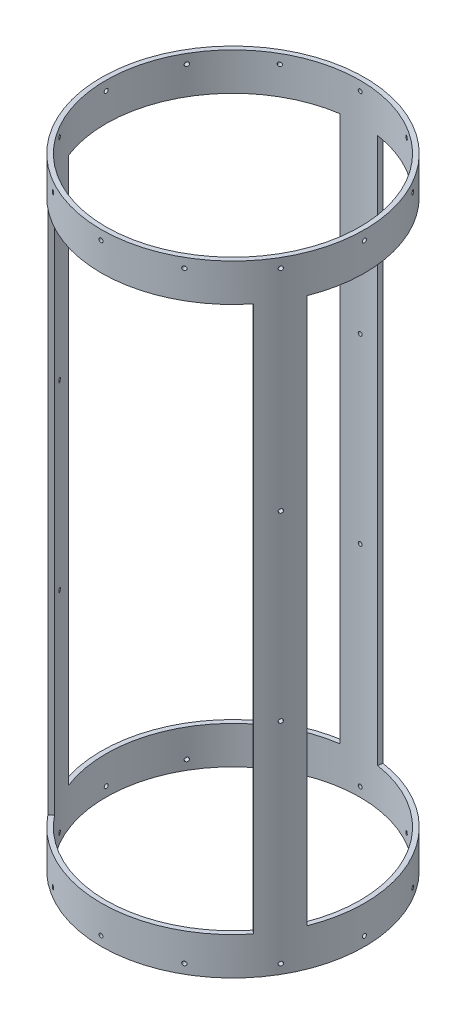
from build123d import *

# Parameters (mm, degrees)
SKETCH1_R               = 88.9
SKETCH1_R_2             = 85.725
BOSS_EXTRUDE1_DEPTH     = 209.55
CUT_EXTRUDE5_START      = -25.4
CUT_EXTRUDE5_DEPTH      = 368.3
CIRPATTERN5_COUNT       = 3
CUT_EXTRUDE2_REACH      = 246.372
CUT_EXTRUDE2_END_RADIUS = 88.9
SKETCH3_R               = 1.35255
CIRPATTERN2_COUNT       = 12
SKETCH4_R               = 1.35255
CUT_EXTRUDE3_DEPTH      = 15.24
CIRPATTERN3_COUNT       = 12
CUT_EXTRUDE4_REACH      = 290.838
SKETCH5_R               = 1.35255
CIRPATTERN4_COUNT       = 3


with BuildPart() as part:
    # Sketch1 → Boss-Extrude1 (new, symmetric)
    with BuildSketch(Plane(origin=(0, 0, 0), x_dir=(1, 0, 0), z_dir=(0, 1, 0))):
        with Locations(Location((0, 0, 0), (0, 0, 270))):
            Circle(SKETCH1_R)
        with Locations(Location((0, 0, 0), (0, 0, 270))):
            Circle(SKETCH1_R_2, mode=Mode.SUBTRACT)
    extrude(amount=BOSS_EXTRUDE1_DEPTH, both=True)

    # Sketch6 → Cut-Extrude5 (cut)
    with BuildSketch(Plane(origin=(0, -209.55, 0), x_dir=(-1, 0, 0), z_dir=(0, -1, 0)).offset(CUT_EXTRUDE5_START)):
        with BuildLine():
            Line((82.79008563, -32.388450433), (79.833296857, -31.23172006))
            ThreePointArc((79.833296857, -31.23172006), (74.185462692, 42.956870815), (12.653594621, 84.785978606))
            Line((12.653594621, 84.785978606), (13.122246274, 87.926200036))
            ThreePointArc((13.122246274, 87.926200036), (76.933072421, 44.54786603), (82.79008563, -32.388450433))
        make_face()
    cut_extrude5 = extrude(amount=-CUT_EXTRUDE5_DEPTH, mode=Mode.SUBTRACT)

    # CirPattern5: Cut-Extrude5 ×3 about axis
    cirpattern5_axis = Axis((0, 0, 0), (0, 1, 0))
    for i in range(1, CIRPATTERN5_COUNT):
        add(cut_extrude5.rotate(cirpattern5_axis, i * 360 / CIRPATTERN5_COUNT), mode=Mode.SUBTRACT)

    # Cut-Extrude2: up to this cylinder (the profile starts inside it)
    cut_extrude2_end = Plane(origin=(0, -203.2, 0), z_dir=(0, -1, 0)) * Cylinder(CUT_EXTRUDE2_END_RADIUS, 671.544, mode=Mode.PRIVATE)
    # Sketch3 → Cut-Extrude2 (cut, up to the surface)
    with BuildSketch(Plane(origin=(0, 0, 0), x_dir=(-1, 0, 0), z_dir=(0, 0, -1)), mode=Mode.PRIVATE) as cut_extrude2_sk1:
        with Locations(Location((-0.169185452, -203.2, 0), (0, 0, 180))):
            Circle(SKETCH3_R)
    cut_extrude2_tool1 = extrude(cut_extrude2_sk1.sketch, amount=CUT_EXTRUDE2_REACH, mode=Mode.PRIVATE) & cut_extrude2_end
    cut_extrude2 = cut_extrude2_tool1.solids().sort_by_distance((0.169185, -203.2, 0))[0]
    add(cut_extrude2, mode=Mode.SUBTRACT)

    # CirPattern2: Cut-Extrude2 ×12 about axis
    cirpattern2_axis = Axis((0, 209.55, 0), (0, -1, 0))
    for i in range(1, CIRPATTERN2_COUNT):
        add(cut_extrude2.rotate(cirpattern2_axis, i * 360 / CIRPATTERN2_COUNT), mode=Mode.SUBTRACT)

    # Sketch4 → Cut-Extrude3 (cut)
    with BuildSketch(Plane(origin=(0, 0, -88.9), x_dir=(-1, 0, 0), z_dir=(0, 0, -1))):
        with Locations(Location((-0.169185452, 203.2, 0), (0, 0, 82.814261444))):
            Circle(SKETCH4_R)
    cut_extrude3 = extrude(amount=-CUT_EXTRUDE3_DEPTH, mode=Mode.SUBTRACT)

    # CirPattern3: Cut-Extrude3 ×12 about axis
    cirpattern3_axis = Axis((0, 209.55, 0), (0, 1, 0))
    for i in range(1, CIRPATTERN3_COUNT):
        add(cut_extrude3.rotate(cirpattern3_axis, i * 360 / CIRPATTERN3_COUNT), mode=Mode.SUBTRACT)

    # Sketch5 → Cut-Extrude4 (cut, up to next)
    with BuildSketch(Plane.XY.offset(88.9), mode=Mode.PRIVATE) as cut_extrude4_sk1:
        with Locations((0.169185452, 61.383333333)):
            Circle(SKETCH5_R)
    cut_extrude4_tool1 = extrude(cut_extrude4_sk1.sketch, amount=-CUT_EXTRUDE4_REACH, mode=Mode.PRIVATE) & part.part
    # Sketch5 → Cut-Extrude4 (cut, up to next)
    with BuildSketch(Plane.XY.offset(88.9), mode=Mode.PRIVATE) as cut_extrude4_sk2:
        with Locations((0.169185452, -61.383333333)):
            Circle(SKETCH5_R)
    cut_extrude4_tool2 = extrude(cut_extrude4_sk2.sketch, amount=-CUT_EXTRUDE4_REACH, mode=Mode.PRIVATE) & part.part
    cut_extrude4_1 = cut_extrude4_tool1.solids().sort_by_distance((0.169185, 61.383333, 88.9))[0]
    add(cut_extrude4_1, mode=Mode.SUBTRACT)
    cut_extrude4_2 = cut_extrude4_tool2.solids().sort_by_distance((0.169185, -61.383333, 88.9))[0]
    add(cut_extrude4_2, mode=Mode.SUBTRACT)
    cut_extrude4 = cut_extrude4_1 + cut_extrude4_2  # Cut-Extrude4 as one shape, for the pattern or mirror that repeats it

    # CirPattern4: Cut-Extrude4 ×3 about axis
    cirpattern4_axis = Axis((0, 209.55, 0), (0, -1, 0))
    for i in range(1, CIRPATTERN4_COUNT):
        add(cut_extrude4.rotate(cirpattern4_axis, i * 360 / CIRPATTERN4_COUNT), mode=Mode.SUBTRACT)


solid = part.part
